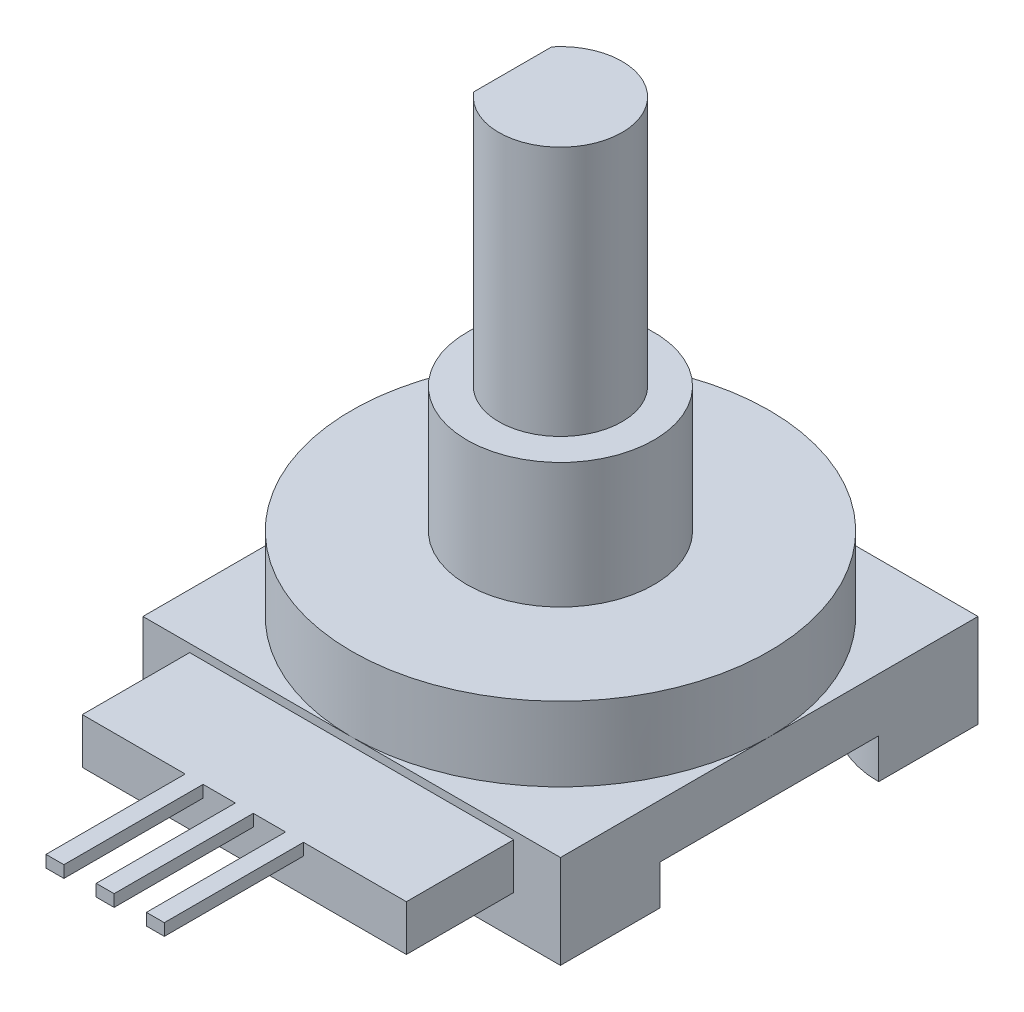
from build123d import *

# Parameters (mm, degrees)
SKETCH1_W               = 21
SKETCH1_H               = 21
BOSS_EXTRUDE1_DEPTH     = 4.7
SKETCH2_R               = 10.5
BOSS_EXTRUDE2_DEPTH     = 3.73
SKETCH3_R               = 4.7
BOSS_EXTRUDE3_DEPTH     = 6.3
SKETCH4_R               = 3.1
BOSS_EXTRUDE4_DEPTH     = 12.6
CUT_EXTRUDE1_DEPTH      = 2
SKETCH6_W               = 16.3
SKETCH6_H               = 2.3
BOSS_EXTRUDE5_DEPTH     = 5.4
SKETCH7_W               = 5.95
SKETCH7_H               = 0.6
BOSS_EXTRUDE6_DEPTH     = 7
SKETCH8_W               = 1.625
SKETCH8_H               = 7
CUT_EXTRUDE2_DEPTH      = 24.03
CUT_EXTRUDE2_DEPTH_BACK = 5.3
CUT_EXTRUDE3_DEPTH      = 9.64


with BuildPart() as part:
    # Sketch1 → Boss-Extrude1 (new body)
    with BuildSketch(Plane(origin=(0, 0, 0), x_dir=(1, 0, 0), z_dir=(0, 1, 0))):
        with Locations((10.5, 10.5)):
            Rectangle(SKETCH1_W, SKETCH1_H)
    extrude(amount=BOSS_EXTRUDE1_DEPTH)

    # Sketch2 → Boss-Extrude2 (add)
    with BuildSketch(Plane(origin=(0, 4.7, 0), x_dir=(1, 0, 0), z_dir=(0, 1, 0))):
        with Locations((10.5, 10.5)):
            Circle(SKETCH2_R)
    extrude(amount=BOSS_EXTRUDE2_DEPTH)

    # Sketch3 → Boss-Extrude3 (add)
    with BuildSketch(Plane(origin=(0, 8.43, 0), x_dir=(1, 0, 0), z_dir=(0, 1, 0))):
        with Locations((10.5, 10.5)):
            Circle(SKETCH3_R)
    extrude(amount=BOSS_EXTRUDE3_DEPTH)

    # Sketch4 → Boss-Extrude4 (add)
    with BuildSketch(Plane(origin=(0, 14.73, 0), x_dir=(1, 0, 0), z_dir=(0, 1, 0))):
        with Locations((10.5, 10.5)):
            Circle(SKETCH4_R)
    extrude(amount=BOSS_EXTRUDE4_DEPTH)

    # Sketch5 → Cut-Extrude1 (cut)
    with BuildSketch(Plane.XZ):
        with BuildLine():
            Line((5, 0), (16, 0))
            ThreePointArc((16, 0), (17.464466094, -3.535533906), (21, -5))
            Line((21, -5), (21, -16))
            ThreePointArc((21, -16), (17.464466094, -17.464466094), (16, -21))
            Line((16, -21), (5, -21))
            ThreePointArc((5, -21), (3.535533906, -17.464466094), (0, -16))
            Line((0, -16), (0, -5))
            ThreePointArc((0, -5), (3.535533906, -3.535533906), (5, 0))
        make_face()
    extrude(amount=-CUT_EXTRUDE1_DEPTH, mode=Mode.SUBTRACT)

    # Sketch6 → Boss-Extrude5 (add)
    with BuildSketch(Plane.XY):
        with Locations((10.5, 3.15)):
            Rectangle(SKETCH6_W, SKETCH6_H)
    extrude(amount=BOSS_EXTRUDE5_DEPTH)

    # Sketch7 → Boss-Extrude6 (add)
    with BuildSketch(Plane.XY.offset(5.4)):
        with Locations((10.5, 4)):
            Rectangle(SKETCH7_W, SKETCH7_H)
    extrude(amount=BOSS_EXTRUDE6_DEPTH)

    # Sketch8 → Cut-Extrude2 (cut, two sides)
    with BuildSketch(Plane(origin=(0, 4.3, 0), x_dir=(1, 0, 0), z_dir=(0, 1, 0))) as cut_extrude2_sk:
        with Locations((9.2375, -8.9)):
            Rectangle(SKETCH8_W, SKETCH8_H)
        with Locations((11.7625, -8.9)):
            Rectangle(SKETCH8_W, SKETCH8_H)
    extrude(amount=CUT_EXTRUDE2_DEPTH, mode=Mode.SUBTRACT)
    extrude(cut_extrude2_sk.sketch, amount=-CUT_EXTRUDE2_DEPTH_BACK, mode=Mode.SUBTRACT)

    # Sketch9 → Cut-Extrude3 (cut)
    with BuildSketch(Plane(origin=(0, 27.33, 0), x_dir=(1, 0, 0), z_dir=(0, 1, 0))):
        with BuildLine():
            Line((8.1, 12.462141687), (8.1, 8.537858313))
            ThreePointArc((8.1, 8.537858313), (7.4, 10.5), (8.1, 12.462141687))
        make_face()
    extrude(amount=-CUT_EXTRUDE3_DEPTH, mode=Mode.SUBTRACT)


solid = part.part
